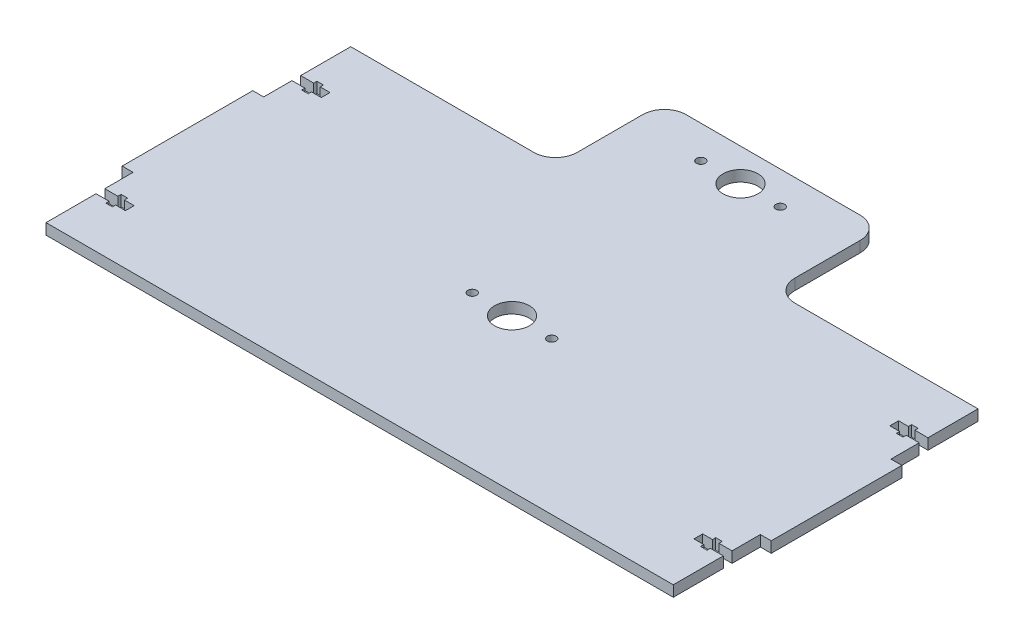
from build123d import *

# Parameters (mm, degrees)
SKETCH1_W           = 288.2
SKETCH1_H           = 140
EXTRUDE_5_DEPTH     = 5
SKETCH2_W           = 10
SKETCH2_H           = 60
BOSS_EXTRUDE2_DEPTH = 5
SKETCH3_W           = 27
SKETCH3_H           = 4
SKETCH3_W_2         = 3
SKETCH3_H_2         = 7
CUT_EXTRUDE1_DEPTH  = 5
SKETCH4_R           = 8
CUT_EXTRUDE2_DEPTH  = 5
SKETCH5_R           = 2
CUT_EXTRUDE3_DEPTH  = 5
SKETCH6_W           = 50
SKETCH6_H           = 50
BOSS_EXTRUDE3_DEPTH = 5
LPATTERN1_COUNT     = 2
LPATTERN1_PITCH     = 105
FILLET1_R           = 10
FILLET2_R           = 10


with BuildPart() as part:
    # Sketch1 → Extrude 5 (new body)
    with BuildSketch(Plane(origin=(0, 0, 0), x_dir=(1, 0, 0), z_dir=(0, 1, 0))):
        Rectangle(SKETCH1_W, SKETCH1_H)
    extrude(amount=EXTRUDE_5_DEPTH)

    # Sketch2 → Boss-Extrude2 (add)
    with BuildSketch(Plane(origin=(0, 5, 0), x_dir=(1, 0, 0), z_dir=(0, 1, 0))):
        with Locations((144.1, 0)):
            Rectangle(SKETCH2_W, SKETCH2_H)
    boss_extrude2 = extrude(amount=-BOSS_EXTRUDE2_DEPTH)

    # Mirror1: Boss-Extrude2 across plane
    add(boss_extrude2.mirror(Plane(origin=(0, 0, 0), x_dir=(0, 0, 1), z_dir=(1, 0, 0))))

    # Sketch3 → Cut-Extrude1 (cut)
    with BuildSketch(Plane(origin=(0, 5, 0), x_dir=(1, 0, 0), z_dir=(0, 1, 0))):
        with Locations((144.1, 45)):
            Rectangle(SKETCH3_W, SKETCH3_H)
        with Locations((136.6, 45)):
            Rectangle(SKETCH3_W_2, SKETCH3_H_2)
        with Locations((136.6, -45)):
            Rectangle(SKETCH3_W_2, SKETCH3_H_2)
        with Locations((144.1, -45)):
            Rectangle(SKETCH3_W, SKETCH3_H)
        with Locations((-144.1, -45)):
            Rectangle(SKETCH3_W, SKETCH3_H)
        with Locations((-136.6, -45)):
            Rectangle(SKETCH3_W_2, SKETCH3_H_2)
        with Locations((-136.6, 45)):
            Rectangle(SKETCH3_W_2, SKETCH3_H_2)
        with Locations((-144.1, 45)):
            Rectangle(SKETCH3_W, SKETCH3_H)
    extrude(amount=-CUT_EXTRUDE1_DEPTH, mode=Mode.SUBTRACT)

    # Sketch4 → Cut-Extrude2 (cut)
    with BuildSketch(Plane(origin=(0, 5, 0), x_dir=(1, 0, 0), z_dir=(0, 1, 0))):
        Circle(SKETCH4_R)
    cut_extrude2 = extrude(amount=-CUT_EXTRUDE2_DEPTH, mode=Mode.SUBTRACT)

    # Sketch5 → Cut-Extrude3 (cut)
    with BuildSketch(Plane(origin=(0, 5, 0), x_dir=(1, 0, 0), z_dir=(0, 1, 0))):
        with Locations((-18.25, 0)):
            Circle(SKETCH5_R)
        with Locations((18.25, 0)):
            Circle(SKETCH5_R)
    cut_extrude3 = extrude(amount=-CUT_EXTRUDE3_DEPTH, mode=Mode.SUBTRACT)

    # Sketch6 → Boss-Extrude3 (add)
    with BuildSketch(Plane(origin=(0, 5, 0), x_dir=(1, 0, 0), z_dir=(0, 1, 0))):
        with Locations((-25, 95)):
            Rectangle(SKETCH6_W, SKETCH6_H)
        with Locations((25, 95)):
            Rectangle(SKETCH6_W, SKETCH6_H)
    extrude(amount=-BOSS_EXTRUDE3_DEPTH)

    # LPattern1: Cut-Extrude2, Cut-Extrude3 ×2
    with Locations(*[(0, 0, -i * LPATTERN1_PITCH) for i in range(1, LPATTERN1_COUNT)]):
        add(cut_extrude2, mode=Mode.SUBTRACT)
        add(cut_extrude3, mode=Mode.SUBTRACT)

    # Fillet1
    fillet1_edges = [part.edges().sort_by_distance(p)[0] for p in [
        (-50, 2.5, -70),
        (50, 2.5, -70),
    ]]
    fillet(fillet1_edges, radius=FILLET1_R)

    # Fillet2
    fillet2_edges = [part.edges().sort_by_distance(p)[0] for p in [
        (-50, 2.5, -120),
        (50, 2.5, -120),
    ]]
    fillet(fillet2_edges, radius=FILLET2_R)


solid = part.part
